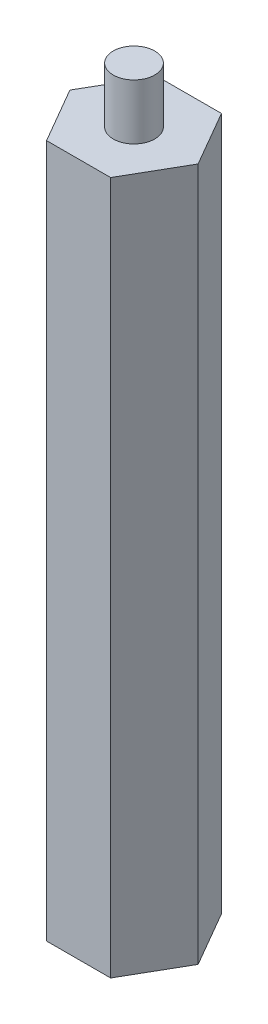
from build123d import *

# Parameters (mm, degrees)
EXTRUDE_1_DEPTH     = 100
SKETCH_2_R          = 3
EXTRUDE_2_DEPTH     = 8
SKETCH_3_R          = 3
CUT_EXTRUDE_1_DEPTH = 8


with BuildPart() as part:
    # 草图1 → 凸台-拉伸1 (new body)
    with BuildSketch(Plane(origin=(0, 0, 0), x_dir=(1, 0, 0), z_dir=(0, 1, 0))):
        Polygon((4.610693432, 8.004676097), (-4.626906133, 7.995315689), (-9.237599565, -0.009360407), (-4.610693432, -8.004676097), (4.626906133, -7.995315689), (9.237599565, 0.009360407), align=None)
    extrude(amount=EXTRUDE_1_DEPTH)

    # 草图2 → 凸台-拉伸2 (add)
    with BuildSketch(Plane(origin=(0, 100, 0), x_dir=(1, 0, 0), z_dir=(0, 1, 0))):
        Circle(SKETCH_2_R)
    extrude(amount=EXTRUDE_2_DEPTH)

    # 草图3 → 切除-拉伸1 (cut)
    with BuildSketch(Plane.XZ):
        Circle(SKETCH_3_R)
    extrude(amount=-CUT_EXTRUDE_1_DEPTH, mode=Mode.SUBTRACT)


solid = part.part
